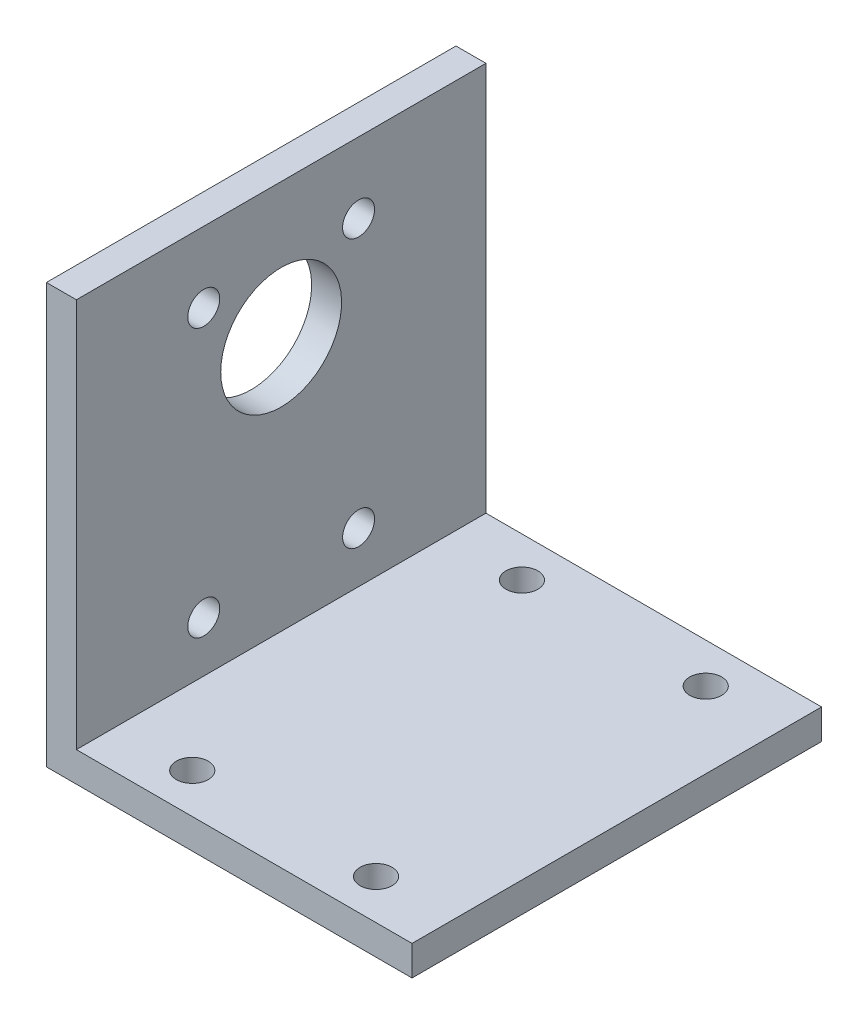
from build123d import *

# Parameters (mm, degrees)
EXTRUDE_1_DEPTH     = 41
SKETCH_2_R          = 6.05
SKETCH_2_R_2        = 1.6
CUT_EXTRUDE_1_DEPTH = 41
SKETCH_3_R          = 1.6
CUT_EXTRUDE_2_DEPTH = 41


with BuildPart() as part:
    # ｽｹｯﾁ1 → ﾎﾞｽ - 押し出し1 (new body)
    with BuildSketch(Plane.XY):
        Polygon((0, 0), (0, 42), (3, 42), (3, 3), (36.6, 3), (36.6, 0), align=None)
    extrude(amount=EXTRUDE_1_DEPTH)

    # ｽｹｯﾁ2 → ｶｯﾄ - 押し出し1 (cut)
    with BuildSketch(Plane.ZY):
        with Locations((20.5, 28.5)):
            Circle(SKETCH_2_R)
        with Locations((28.25, 34.925)):
            Circle(SKETCH_2_R_2)
        with Locations((28.25, 8.075)):
            Circle(SKETCH_2_R_2)
        with Locations((12.75, 8.075)):
            Circle(SKETCH_2_R_2)
        with Locations((12.75, 34.925)):
            Circle(SKETCH_2_R_2)
    extrude(amount=-CUT_EXTRUDE_1_DEPTH, mode=Mode.SUBTRACT)

    # ｽｹｯﾁ3 → ｶｯﾄ - 押し出し2 (cut)
    with BuildSketch(Plane(origin=(0, 0, 0), x_dir=(-1, 0, 0), z_dir=(0, -1, 0))):
        with Locations((-10.6, -37)):
            Circle(SKETCH_3_R)
        with Locations((-10.6, -4)):
            Circle(SKETCH_3_R)
        with Locations((-29, -4)):
            Circle(SKETCH_3_R)
        with Locations((-29, -37)):
            Circle(SKETCH_3_R)
    extrude(amount=-CUT_EXTRUDE_2_DEPTH, mode=Mode.SUBTRACT)


solid = part.part
